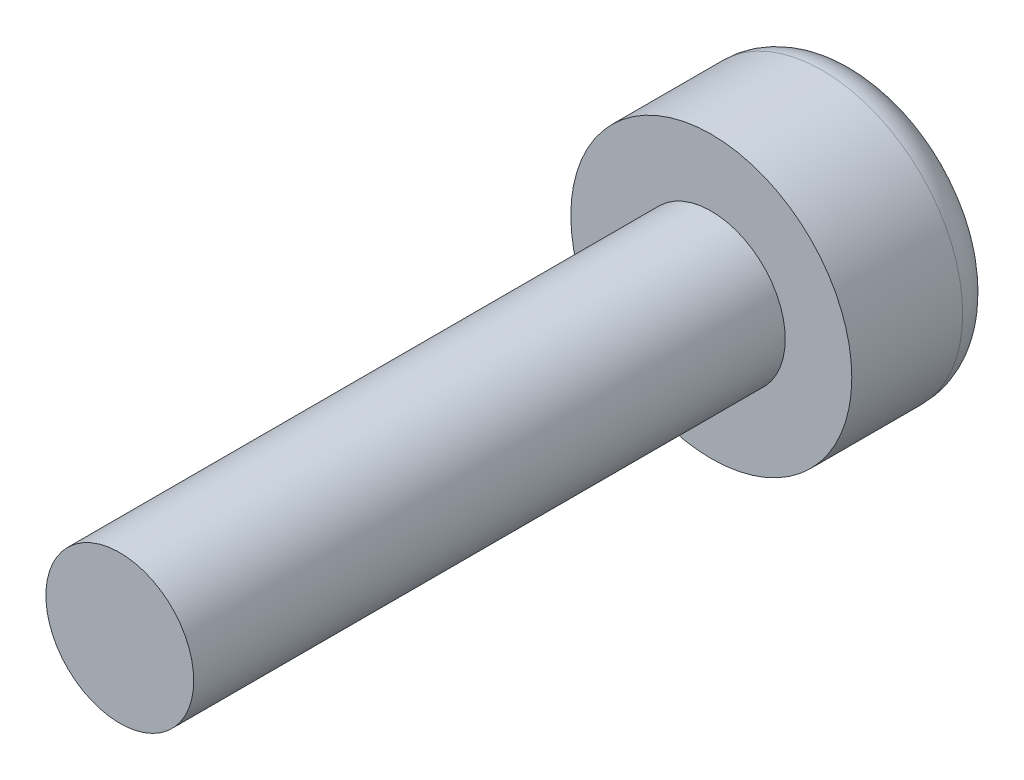
from build123d import *

# Parameters (mm, degrees)
SKETCH_2_R      = 1.9
EXTRUDE_1_DEPTH = 2
SKETCH_3_R      = 1
EXTRUDE_2_DEPTH = 8
FILLET_1_R      = 0.5


with BuildPart() as part:
    # ｽｹｯﾁ2 → ﾎﾞｽ - 押し出し1 (new body)
    with BuildSketch(Plane.XY):
        Circle(SKETCH_2_R)
    extrude(amount=EXTRUDE_1_DEPTH)

    # ｽｹｯﾁ3 → ﾎﾞｽ - 押し出し2 (add)
    with BuildSketch(Plane.XY.offset(2)):
        Circle(SKETCH_3_R)
    extrude(amount=EXTRUDE_2_DEPTH)

    # ﾌｨﾚｯﾄ1
    fillet_1_edges = [part.edges().sort_by_distance(p)[0] for p in [
        (-1.9, 0, 0),
    ]]
    fillet(fillet_1_edges, radius=FILLET_1_R)


solid = part.part
